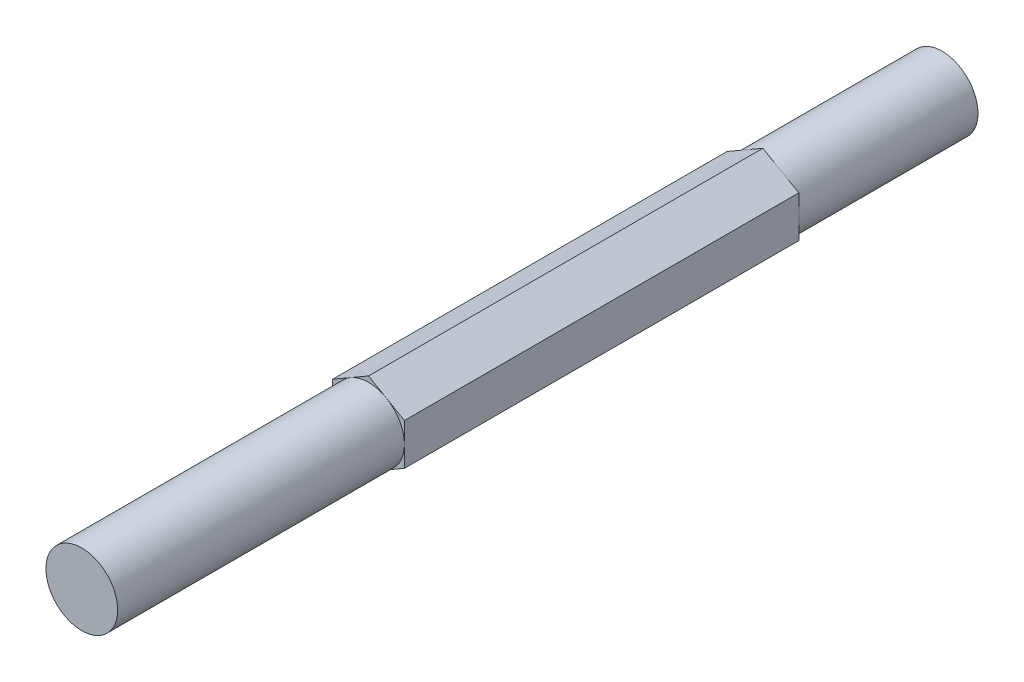
from build123d import *

# Parameters (mm, degrees)
BOSS_EXTRUDE1_DEPTH = 76.2
SKETCH3_OUTSIDE_W   = 23.712
SKETCH3_OUTSIDE_H   = 24.694
SKETCH3_OUTSIDE_R   = 3.175
CUT_EXTRUDE1_DEPTH  = 25.4
SKETCH4_OUTSIDE_W   = 23.712
SKETCH4_OUTSIDE_H   = 24.694
SKETCH4_OUTSIDE_R   = 3.175
CUT_EXTRUDE2_DEPTH  = 15.875


with BuildPart() as part:
    # Sketch2 → Boss-Extrude1 (new body)
    with BuildSketch(Plane.XY):
        Polygon((0, 3.666174209), (-3.175, 1.833087105), (-3.175, -1.833087105), (0, -3.666174209), (3.175, -1.833087105), (3.175, 1.833087105), align=None)
    extrude(amount=BOSS_EXTRUDE1_DEPTH)

    # Sketch3 outside → Cut-Extrude1 (cut)
    with BuildSketch(Plane.XY.offset(76.2)):
        Rectangle(SKETCH3_OUTSIDE_W, SKETCH3_OUTSIDE_H)
        Circle(SKETCH3_OUTSIDE_R, mode=Mode.SUBTRACT)
    extrude(amount=-CUT_EXTRUDE1_DEPTH, mode=Mode.SUBTRACT)

    # Sketch4 outside → Cut-Extrude2 (cut)
    with BuildSketch(Plane(origin=(0, 0, 0), x_dir=(-1, 0, 0), z_dir=(0, 0, -1))):
        Rectangle(SKETCH4_OUTSIDE_W, SKETCH4_OUTSIDE_H)
        Circle(SKETCH4_OUTSIDE_R, mode=Mode.SUBTRACT)
    extrude(amount=-CUT_EXTRUDE2_DEPTH, mode=Mode.SUBTRACT)


solid = part.part
